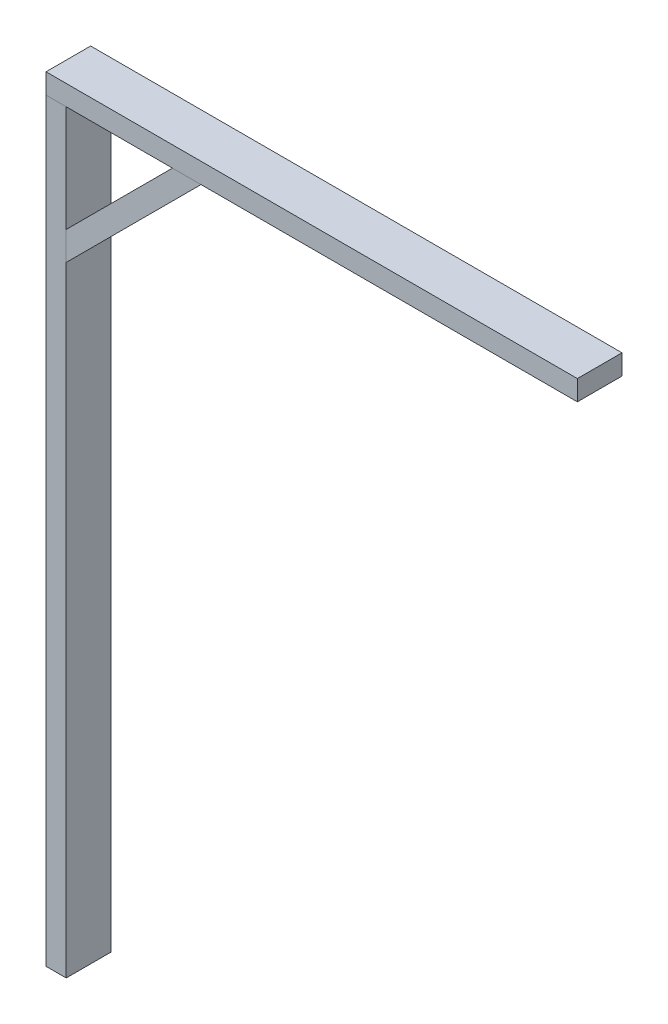
from build123d import *

# Parameters (mm, degrees)
CROQUIS1_W              = 19
CROQUIS1_H              = 42
SALIENTE_EXTRUIR1_DEPTH = 710
CROQUIS2_W              = 42
CROQUIS2_H              = 19
SALIENTE_EXTRUIR2_DEPTH = 500
SALIENTE_EXTRUIR3_DEPTH = 42


with BuildPart() as part:
    # Croquis1 → Saliente-Extruir1 (new body)
    with BuildSketch(Plane(origin=(0, 0, 0), x_dir=(1, 0, 0), z_dir=(0, 1, 0))):
        Rectangle(CROQUIS1_W, CROQUIS1_H)
    extrude(amount=SALIENTE_EXTRUIR1_DEPTH)


with BuildPart() as body_2:
    # Croquis2 → Saliente-Extruir2 (new body)
    with BuildSketch(Plane.ZY.offset(9.5)):
        with Locations((0, 719.5)):
            Rectangle(CROQUIS2_W, CROQUIS2_H)
    extrude(amount=-SALIENTE_EXTRUIR2_DEPTH)


with BuildPart() as body_3:
    # Croquis3 → Saliente-Extruir3 (new body)
    with BuildSketch(Plane.XY.offset(21)):
        Polygon((9.5, 610), (9.5, 583.129942315), (136.370057685, 710), (109.5, 710), align=None)
    extrude(amount=-SALIENTE_EXTRUIR3_DEPTH)


solid = Compound([part.part, body_2.part, body_3.part])
